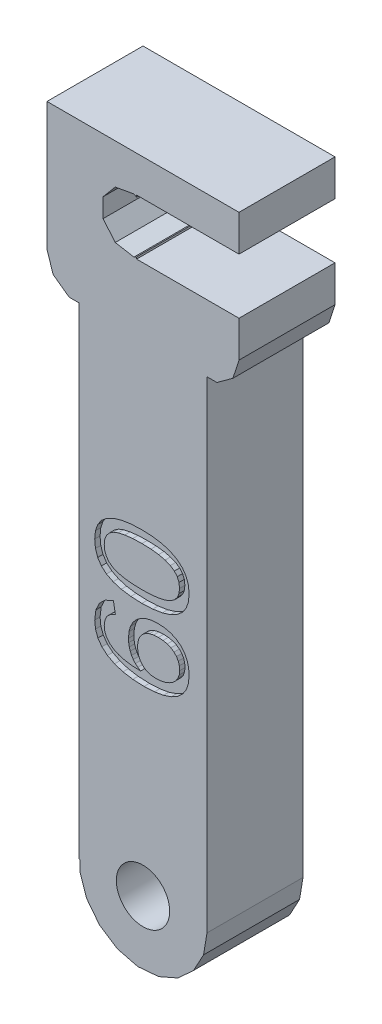
from build123d import *

# Parameters (mm, degrees)
BOSS_EXTRUDE1_DEPTH = 8.999999613
CUT_EXTRUDE1_DEPTH  = 9.999999613
CUT_EXTRUDE2_DEPTH  = 9.999999613
CUT_EXTRUDE3_DEPTH  = 0.499999616
BOSS_EXTRUDE2_DEPTH = 0.499999616
CUT_EXTRUDE4_DEPTH  = 0.499999616
BOSS_EXTRUDE3_DEPTH = 0.499999616
DRAFT1_ANGLE        = -30.003327488
SKETCH8_R           = 2.500025683
CUT_EXTRUDE5_DEPTH  = 9.999999613


with BuildPart() as part:
    # Sketch1 → Boss-Extrude1 (new body)
    with BuildSketch(Plane.XY.offset(4.499999806)):
        Polygon((8.427049965, 16.236599535), (8.999999613, 17.999999225), (8.999999613, 29.999999329), (-8.999999613, 29.999999329), (-8.999999613, 17.999999225), (-8.427049965, 16.236599535), (-6.927050184, 15.146800317), (-6.000000052, 15.146800317), (-6.000000052, -29.999999329), (-5.91816986, -29.999999329), (-5.91816986, -30.987599865), (-5.27684018, -32.855700701), (-4.063690081, -34.414298832), (-2.410169924, -35.494599491), (-0.495476008, -35.979498178), (1.472910051, -35.816401243), (3.281689947, -35.023000091), (4.734839778, -33.685300499), (5.674900021, -31.948201358), (6.000000052, -29.999999329), (6.000000052, 15.146800317), (6.927050184, 15.146800317), align=None)
    extrude(amount=-BOSS_EXTRUDE1_DEPTH)

    # Sketch2 → Cut-Extrude1 (cut, through all)
    with BuildSketch(Plane(origin=(0, 0, -4.499999806), x_dir=(-1, 0, 0), z_dir=(0, 0, -1))):
        Polygon((-8.999999613, 26.599999517), (-8.999999613, 21.4000009), (0.599998981, 21.4000009), (0.599998981, 21.583000198), (0.848515017, 21.439500153), (2.600000007, 21.748300642), (3.743200097, 23.110700771), (3.743200097, 24.889299646), (2.600000007, 26.251699775), (1.662432689, 26.417000219), (0.599998981, 26.417000219), (0.599998981, 26.599999517), align=None)
    extrude(amount=-CUT_EXTRUDE1_DEPTH, mode=Mode.SUBTRACT)

    # Sketch3 → Cut-Extrude2 (cut, through all)
    with BuildSketch(Plane(origin=(0, 0, -4.499999806), x_dir=(-1, 0, 0), z_dir=(0, 0, -1))):
        Polygon((1.767770038, -28.232200071), (0, -27.499999851), (-1.767770038, -28.232200071), (-2.499999944, -29.999999329), (-1.767770038, -31.76780045), (0, -32.499998808), (1.767770038, -31.76780045), (2.499999944, -29.999999329), align=None)
    extrude(amount=-CUT_EXTRUDE2_DEPTH, mode=Mode.SUBTRACT)

    # Sketch4 → Cut-Extrude3 (cut)
    with BuildSketch(Plane.XY.offset(4.499999806)):
        Polygon((-2.584839938, -8.463440463), (-2.774019958, -7.4136802), (-3.540330101, -7.756989915), (-4.087709822, -8.280349895), (-4.416119773, -8.983730339), (-4.525600001, -9.86715965), (-4.450839944, -10.563299991), (-4.226529971, -11.174799874), (-3.852690104, -11.701500043), (-3.329320112, -12.143599801), (-2.666380024, -12.493399903), (-1.873750007, -12.743200175), (-0.951430993, -12.893100269), (0.100571, -12.943100184), (1.070600003, -12.895000167), (1.917800051, -12.750900351), (2.642180072, -12.510599568), (3.243729938, -12.174099684), (3.716310021, -11.746900156), (4.053859971, -11.234300211), (4.256390035, -10.636099614), (4.32390999, -9.952579625), (4.274699837, -9.337689728), (4.127109889, -8.792979643), (3.881090088, -8.318480104), (3.536680015, -7.914169692), (3.107160097, -7.591090165), (2.605929971, -7.360320073), (2.032960067, -7.22185988), (1.388289966, -7.175719831), (0.791718019, -7.219390012), (0.259232009, -7.350429893), (-0.209152, -7.568819914), (-0.613479991, -7.874559611), (-0.939223974, -8.254650049), (-1.171909971, -8.696150035), (-1.311509986, -9.199069813), (-1.358050038, -9.76340007), (-1.339940005, -10.104400106), (-1.285569975, -10.425600223), (-1.194979995, -10.727000423), (-1.068160054, -11.008500122), (-0.906615984, -11.264800094), (-0.711899018, -11.490600184), (-0.483977987, -11.68590039), (-0.222870003, -11.850699782), (-1.003889949, -11.818399653), (-1.686859992, -11.721800081), (-2.271800069, -11.560600251), (-2.758709947, -11.335000396), (-3.141880035, -11.050599627), (-3.415559884, -10.713200085), (-3.579769982, -10.322799906), (-3.634510096, -9.879410267), (-3.568910062, -9.381210431), (-3.372089937, -8.979160339), (-3.044069977, -8.673230186), align=None)
    extrude(amount=-CUT_EXTRUDE3_DEPTH, mode=Mode.SUBTRACT)

    # Sketch5 → Boss-Extrude2 (add)
    with BuildSketch(Plane.XY.offset(4.00000019)):
        Polygon((3.280269913, -10.688800365), (3.081920091, -10.986600071), (2.804260002, -11.249599978), (2.464370104, -11.464499868), (2.079480095, -11.618000455), (1.649599988, -11.710099876), (1.174709992, -11.740799993), (0.802231021, -11.711199768), (0.472092011, -11.622499675), (0.184296005, -11.474699713), (-0.061141996, -11.267799884), (-0.257384992, -11.012800038), (-0.397567987, -10.720799677), (-0.481674011, -10.391799733), (-0.509704987, -10.025800206), (-0.478042988, -9.639419615), (-0.383056991, -9.298020042), (-0.224746997, -9.001630358), (-0.00309753, -8.750259876), (0.276854989, -8.550000377), (0.610214018, -8.406950161), (0.996978953, -8.321139961), (1.437159954, -8.292529732), (1.879059942, -8.320759982), (2.27098004, -8.405460045), (2.612960059, -8.546619676), (2.904969966, -8.744229563), (3.138579894, -8.991389535), (3.305450082, -9.281280451), (3.405560041, -9.613890201), (3.438930027, -9.98920016), (3.3992799, -10.356400162), align=None)
    extrude(amount=BOSS_EXTRUDE2_DEPTH)

    # Sketch6 → Cut-Extrude4 (cut)
    with BuildSketch(Plane.XY.offset(4.499999806)):
        Polygon((-1.139129978, -6.255479995), (-0.100830002, -6.300670095), (0.917633006, -6.254139822), (1.80641003, -6.114529911), (2.56548007, -5.881850142), (3.194849938, -5.556109827), (3.688809928, -5.137660075), (4.041640088, -4.626910202), (4.253339954, -4.023820162), (4.32390999, -3.328430001), (4.252959974, -2.632129937), (4.04012017, -2.026210073), (3.685380099, -1.510730013), (3.188739996, -1.085630036), (2.557449974, -0.753188971), (1.798750018, -0.515731983), (0.912658987, -0.373245013), (-0.100830002, -0.325759989), (-1.129230019, -0.370955997), (-2.023329958, -0.506561017), (-2.783159958, -0.732573972), (-3.408689983, -1.048999955), (-3.897340037, -1.460360014), (-4.246369936, -1.971269958), (-4.455800168, -2.581760054), (-4.525600001, -3.291789908), (-4.456560127, -4.020549823), (-4.24944004, -4.644410219), (-3.90421995, -5.163379945), (-3.420939902, -5.577439908), (-2.799180103, -5.893860012), (-2.038589912, -6.119870115), align=None)
    extrude(amount=-CUT_EXTRUDE4_DEPTH, mode=Mode.SUBTRACT)

    # Sketch7 → Boss-Extrude3 (add)
    with BuildSketch(Plane.XY.offset(4.00000019)):
        Polygon((-2.798399888, -1.872860012), (-2.316270024, -1.684600022), (-1.705960021, -1.550139976), (-0.967484026, -1.469469978), (-0.100830002, -1.442570006), (0.738342002, -1.470790012), (1.461560023, -1.555470051), (2.068849979, -1.696610008), (2.560179913, -1.894179964), (2.939319937, -2.152420115), (3.210129915, -2.475519897), (3.372620093, -2.863459988), (3.426790005, -3.316279966), (3.373760032, -3.771529999), (3.214709926, -4.160800017), (2.949600108, -4.484049976), (2.578449901, -4.741330165), (2.092859941, -4.937579855), (1.484449953, -5.077760201), (0.753219996, -5.161869805), (-0.100830002, -5.189899821), (-0.977386022, -5.162249785), (-1.721190056, -5.079280119), (-2.33224011, -4.941020161), (-2.810559934, -4.747449886), (-3.171039978, -4.490519874), (-3.428509925, -4.162279889), (-3.583010053, -3.762699896), (-3.634510096, -3.291789908), (-3.582240082, -2.832370112), (-3.425480099, -2.442729892), (-3.164200112, -2.122889971), align=None)
    extrude(amount=BOSS_EXTRUDE3_DEPTH)

    # Draft1
    draft1_faces = [part.faces().sort_by_distance(p)[0] for p in [
        (-1.131215835, 26.417000219, 0),
    ]]
    draft(draft1_faces, Plane(origin=(-0.599998981, 26.417000219, 4.499999806), x_dir=(0, 0, 1), z_dir=(1, 0, 0)), DRAFT1_ANGLE)

    # Sketch8 → Cut-Extrude5 (cut, through all)
    with BuildSketch(Plane.XY.offset(4.499999806)):
        with Locations((0, -30.000000261)):
            Circle(SKETCH8_R)
    extrude(amount=-CUT_EXTRUDE5_DEPTH, mode=Mode.SUBTRACT)


solid = part.part
